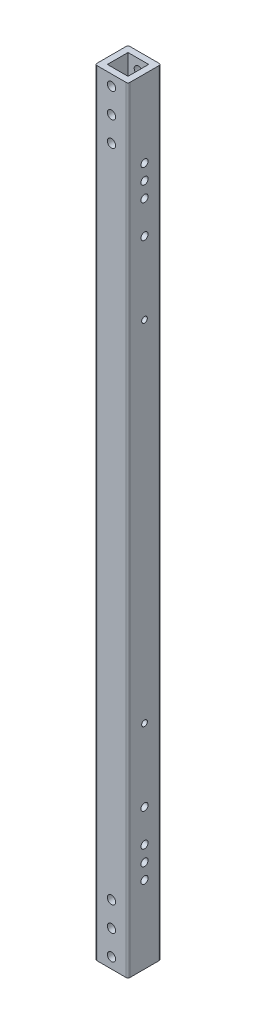
from build123d import *

# Parameters (mm, degrees)
SKETCH1_W                   = 25.4
SKETCH1_H                   = 25.4
SKETCH1_W_2                 = 15.875
SKETCH1_H_2                 = 15.875
BOSS_EXTRUDE1_DEPTH         = 298
FILLET1_R                   = 1.5
F_1_4_0_25_DIAMETER_HOLE1_D = 6.35
SKETCH4_R                   = 2.2
SKETCH4_R_2                 = 2.75
CUT_EXTRUDE1_DEPTH          = 26.4


with BuildPart() as part:
    # Sketch1 → Boss-Extrude1 (new body, symmetric)
    with BuildSketch(Plane(origin=(0, 0, 0), x_dir=(1, 0, 0), z_dir=(0, 1, 0))):
        Rectangle(SKETCH1_W, SKETCH1_H)
        Rectangle(SKETCH1_W_2, SKETCH1_H_2, mode=Mode.SUBTRACT)
    extrude(amount=BOSS_EXTRUDE1_DEPTH, both=True)

    # Fillet1
    fillet1_edges = [part.edges().sort_by_distance(p)[0] for p in [
        (12.7, 0, 12.7),
        (-12.7, 0, 12.7),
        (-12.7, 0, -12.7),
        (12.7, 0, -12.7),
    ]]
    fillet(fillet1_edges, radius=FILLET1_R)

    # 1/4 (0.25) Diameter Hole1 (through all)
    with Locations(Plane(origin=(0.011805537, 289.825, -12.7), x_dir=(-1, 0, 0), z_dir=(0, 0, -1))):
        with Locations((0, 0), (0, -19), (0, -38)):
            f_1_4_0_25_diameter_hole1 = Hole(F_1_4_0_25_DIAMETER_HOLE1_D / 2)

    # Mirror1: 1/4 (0.25) Diameter Hole1 across plane
    add(f_1_4_0_25_diameter_hole1.mirror(Plane.ZX), mode=Mode.SUBTRACT)

    # Sketch4 → Cut-Extrude1 (cut, through all)
    with BuildSketch(Plane.ZY.offset(12.7)):
        with Locations((0, 134.3)):
            Circle(SKETCH4_R)
        with Locations((0, -134.3)):
            Circle(SKETCH4_R)
        with Locations((0, 238.65)):
            Circle(SKETCH4_R_2)
        with Locations((0, 226.9)):
            Circle(SKETCH4_R_2)
        with Locations((0, 215.15)):
            Circle(SKETCH4_R_2)
        with Locations((0, -215.15)):
            Circle(SKETCH4_R_2)
        with Locations((0, -226.9)):
            Circle(SKETCH4_R_2)
        with Locations((0, -238.65)):
            Circle(SKETCH4_R_2)
        with Locations((0, 190)):
            Circle(SKETCH4_R_2)
        with Locations((0, -190)):
            Circle(SKETCH4_R_2)
    extrude(amount=-CUT_EXTRUDE1_DEPTH, mode=Mode.SUBTRACT)


solid = part.part
